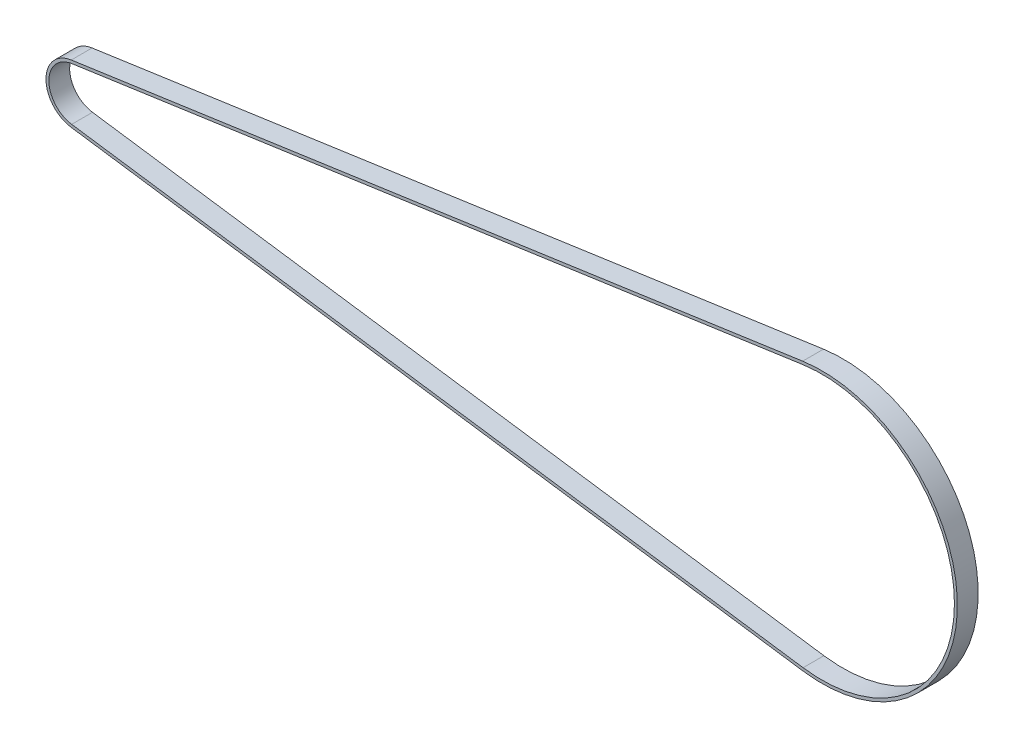
from build123d import *

# Parameters (mm, degrees)
EXTRUDE_THIN1_DEPTH = 14.224


with BuildPart() as part:
    # Sketch2 → Extrude-Thin1 (new body)
    with BuildSketch(Plane.XY):
        with BuildLine():
            Line((496.863202176, -91.613929858), (-2.861676059, -19.956871777))
            ThreePointArc((-2.861676059, -19.956871777), (-20.161, 0), (-2.861676059, 19.956871777))
            Line((-2.861676059, 19.956871777), (496.863202176, 91.613929858))
            ThreePointArc((496.863202176, 91.613929858), (602.551, 0), (496.863202176, -91.613929858))
        make_face()
        with BuildLine():
            Line((497.147084529, -89.634179669), (-2.577793706, -17.977121589))
            ThreePointArc((-2.577793706, -17.977121589), (-18.161, 0), (-2.577793706, 17.977121589))
            Line((-2.577793706, 17.977121589), (497.147084529, 89.634179669))
            ThreePointArc((497.147084529, 89.634179669), (600.551, 0), (497.147084529, -89.634179669))
        make_face(mode=Mode.SUBTRACT)
    extrude(amount=EXTRUDE_THIN1_DEPTH)


solid = part.part
